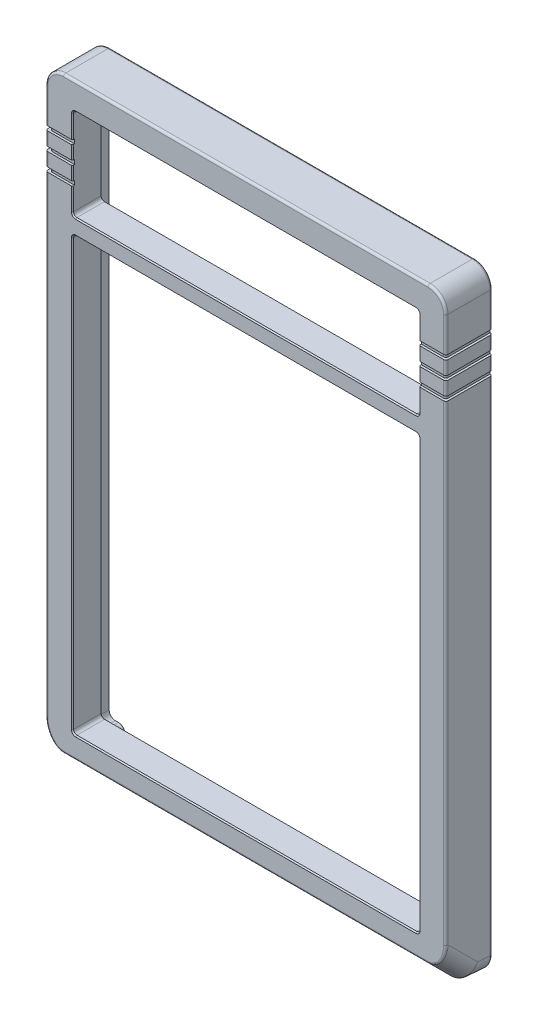
from build123d import *

# Parameters (mm, degrees)
EXTRUDE_1_DEPTH       = 89.5
SKETCH_2_OUTSIDE_W    = 124.308
SKETCH_2_OUTSIDE_H    = 171.808
SKETCH_2_OUTSIDE_W_2  = 86.3
SKETCH_2_OUTSIDE_H_2  = 133.9
CUT_EXTRUDE_1_DEPTH   = 1
SKETCH_5_R            = 0.9
CUT_EXTRUDE_3_DEPTH   = 6
CUT_EXTRUDE_4_DEPTH   = 5
FILLET_1_R            = 1.4
FILLET_2_R            = 1.4
SKETCH_3_W            = 77.5
SKETCH_3_H            = 96.7
SKETCH_3_H_2          = 20.5
CUT_EXTRUDE_2_DEPTH   = 11.4
FILLET_9_R            = 0.75
FILLET_4_R            = 4
FILLET_7_R            = 2.2
FILLET_8_R            = 0.5
CHAMFER_1_SIZE        = 0.25
SKETCH_7_W            = 102.586971925
SKETCH_7_H            = 1
SKETCH_7_W_2          = 99.317091084
SKETCH_7_W_3          = 97.717091046
CUT_EXTRUDE_1_2_DEPTH = 0.5
SKETCH_8_W            = 14.455899317
SKETCH_8_H            = 1
SKETCH_8_W_2          = 13.955899317
SKETCH_8_W_3          = 15.127945799
CUT_EXTRUDE_2_2_DEPTH = 0.5
SKETCH_9_W            = 13.549012079
SKETCH_9_H            = 1
SKETCH_9_W_2          = 13.424709216
CUT_EXTRUDE_3_2_DEPTH = 0.5
FILLET_10_R           = 0.5


with BuildPart() as part:
    # 草图1 → 凸台-拉伸1 (new body)
    with BuildSketch(Plane(origin=(0, 0, 0), x_dir=(0, 0, -1), z_dir=(1, 0, 0))):
        Polygon((0, 0), (0, 137), (-11.4, 137), (-11.4, 5.716942107), (-6.13205448, 0.448996588), (-1, 0), align=None)
    extrude(amount=EXTRUDE_1_DEPTH)

    # 草图2 outside → Cut-Extrude 1 (cut)
    with BuildSketch(Plane(origin=(0, 0, 0), x_dir=(-1, 0, 0), z_dir=(0, 0, -1))):
        with Locations((-44.75, 68.5)):
            Rectangle(SKETCH_2_OUTSIDE_W, SKETCH_2_OUTSIDE_H)
        with Locations((-44.75, 68.45)):
            Rectangle(SKETCH_2_OUTSIDE_W_2, SKETCH_2_OUTSIDE_H_2, mode=Mode.SUBTRACT)
    extrude(amount=-CUT_EXTRUDE_1_DEPTH, mode=Mode.SUBTRACT)

    # 草图5 → Cut-Extrude 3 (cut)
    with BuildSketch(Plane(origin=(0, 0, 0), x_dir=(-1, 0, 0), z_dir=(0, 0, -1))):
        with Locations((-84.95, 4.55)):
            Circle(SKETCH_5_R)
        with Locations((-4.55, 4.55)):
            Circle(SKETCH_5_R)
        with Locations((-4.55, 132.45)):
            Circle(SKETCH_5_R)
        with Locations((-84.95, 132.45)):
            Circle(SKETCH_5_R)
    extrude(amount=-CUT_EXTRUDE_3_DEPTH, mode=Mode.SUBTRACT)

    # 草图6 → 切除-拉伸4 (cut)
    with BuildSketch(Plane(origin=(0, 0, 0), x_dir=(-1, 0, 0), z_dir=(0, 0, -1))):
        Polygon((-83.2, 2.7), (-6.3, 2.7), (-6.3, 6.2), (-2.8, 6.2), (-2.8, 70.55), (-2.8, 130.7), (-6.3, 130.7), (-6.3, 134.2), (-83.2, 134.2), (-83.2, 130.7), (-86.7, 130.7), (-86.7, 74.35), (-86.7, 6.2), (-83.2, 6.2), align=None)
    extrude(amount=-CUT_EXTRUDE_4_DEPTH, mode=Mode.SUBTRACT)

    # 圆角1
    fillet_1_edges = [part.edges().sort_by_distance(p)[0] for p in [
        (83.2, 2.7, 2.5),
        (86.7, 6.2, 2.5),
        (86.7, 130.7, 2.5),
        (83.2, 134.2, 2.5),
        (6.3, 134.2, 2.5),
        (2.8, 130.7, 2.5),
        (2.8, 6.2, 2.5),
        (6.3, 2.7, 2.5),
    ]]
    fillet(fillet_1_edges, radius=FILLET_1_R)

    # 圆角2
    fillet_2_edges = [part.edges().sort_by_distance(p)[0] for p in [
        (83.2, 6.2, 2.5),
        (83.2, 130.7, 2.5),
        (6.3, 130.7, 2.5),
        (6.3, 6.2, 2.5),
    ]]
    fillet(fillet_2_edges, radius=FILLET_2_R)

    # 草图3 → Cut-Extrude 2 (cut)
    with BuildSketch(Plane(origin=(0, 0, 0), x_dir=(-1, 0, 0), z_dir=(0, 0, -1))):
        with Locations((-44.75, 58.6)):
            Rectangle(SKETCH_3_W, SKETCH_3_H)
        with Locations((-44.75, 120.75)):
            Rectangle(SKETCH_3_W, SKETCH_3_H_2)
    extrude(amount=-CUT_EXTRUDE_2_DEPTH, mode=Mode.SUBTRACT)

    # 圆角9
    fillet_9_edges = [part.edges().sort_by_distance(p)[0] for p in [
        (6, 106.95, 8.2),
        (6, 10.25, 8.2),
        (83.5, 10.25, 8.2),
        (83.5, 106.95, 8.2),
        (83.5, 110.5, 8.2),
        (83.5, 131, 8.2),
        (6, 131, 8.2),
        (6, 110.5, 8.2),
    ]]
    fillet(fillet_9_edges, radius=FILLET_9_R)

    # 圆角4
    fillet_4_edges = [part.edges().sort_by_distance(p)[0] for p in [
        (0, 137, 6.2),
        (89.5, 137, 6.2),
        (89.5, 3.082969348, 8.76602724),
        (89.5, 0.224498294, 3.56602724),
        (0, 0.224498294, 3.56602724),
        (0, 3.082969348, 8.76602724),
    ]]
    fillet(fillet_4_edges, radius=FILLET_4_R)

    # 圆角7
    fillet_7_edges = [part.edges().sort_by_distance(p)[0] for p in [
        (87.9, 135.4, 0.5),
        (1.6, 135.4, 0.5),
        (1.6, 1.5, 0.5),
        (87.9, 1.5, 0.5),
    ]]
    fillet(fillet_7_edges, radius=FILLET_7_R)

    # 圆角8
    fillet_8_edges = [part.edges().sort_by_distance(p)[0] for p in [
        (89.5, 68.507639675, 1),
        (89.5, 72.186898178, 11.4),
        (44.75, 0.448996588, 6.13205448),
        (44.75, 5.716942107, 11.4),
        (0, 72.186898178, 11.4),
        (44.75, 137, 11.4),
        (88.328427125, 135.828427125, 11.4),
        (1.171572875, 135.828427125, 11.4),
        (0.946815933, 7.71919185, 11.4),
        (88.553184067, 7.71919185, 11.4),
        (44.75, 0, 1),
        (0, 68.507639675, 1),
        (44.75, 137, 1),
        (88.328427125, 135.828427125, 1),
        (1.171572875, 135.828427125, 1),
        (1.168878288, 1.178755553, 1),
        (88.331121712, 1.178755553, 1),
        (88.372004479, 1.621633445, 5.585244933),
        (1.127995521, 1.621633445, 5.585244933),
        (44.75, 1.5, 0),
        (87.9, 68.45, 0),
        (1.6, 68.45, 0),
        (44.75, 135.4, 0),
        (87.255634919, 134.755634919, 0),
        (2.244365081, 134.755634919, 0),
        (87.255634919, 2.144365081, 0),
        (2.244365081, 2.144365081, 0),
    ]]
    fillet(fillet_8_edges, radius=FILLET_8_R)

    # 倒角1
    chamfer_1_edges = [part.edges().sort_by_distance(p)[0] for p in [
        (6, 120.75, 11.4),
        (44.75, 110.5, 11.4),
        (83.5, 120.75, 11.4),
        (44.75, 131, 11.4),
        (83.5, 58.6, 11.4),
        (44.75, 106.95, 11.4),
        (6, 58.6, 11.4),
        (44.75, 10.25, 11.4),
        (6.219669914, 110.719669914, 11.4),
        (83.280330086, 110.719669914, 11.4),
        (6.219669914, 130.780330086, 11.4),
        (83.280330086, 130.780330086, 11.4),
        (83.280330086, 106.730330086, 11.4),
        (6.219669914, 106.730330086, 11.4),
        (6.219669914, 10.469669914, 11.4),
        (83.280330086, 10.469669914, 11.4),
    ]]
    chamfer(chamfer_1_edges, length=CHAMFER_1_SIZE)

    # 草图7 → Cut-Extrude 1 2 (cut)
    with BuildSketch(Plane.XY.offset(11.4)):
        with Locations((44.090920782, 120.75)):
            Rectangle(SKETCH_7_W, SKETCH_7_H)
        with Locations((43.658545504, 124.75)):
            Rectangle(SKETCH_7_W_2, SKETCH_7_H)
        with Locations((44.458545523, 116.75)):
            Rectangle(SKETCH_7_W_3, SKETCH_7_H)
    extrude(amount=-CUT_EXTRUDE_1_2_DEPTH, mode=Mode.SUBTRACT)

    # 草图8 → Cut-Extrude 2 2 (cut)
    with BuildSketch(Plane(origin=(89.5, 0, 0), x_dir=(0, 0, -1), z_dir=(1, 0, 0))):
        with Locations((-7.227949659, 124.75)):
            Rectangle(SKETCH_8_W, SKETCH_8_H)
        with Locations((-7.477949659, 116.75)):
            Rectangle(SKETCH_8_W_2, SKETCH_8_H)
        with Locations((-6.891926417, 120.75)):
            Rectangle(SKETCH_8_W_3, SKETCH_8_H)
    extrude(amount=-CUT_EXTRUDE_2_2_DEPTH, mode=Mode.SUBTRACT)

    # 草图9 → Cut-Extrude 3 2 (cut)
    with BuildSketch(Plane.ZY):
        with Locations((5.610494664, 124.75)):
            Rectangle(SKETCH_9_W, SKETCH_9_H)
        with Locations((5.610494664, 116.75)):
            Rectangle(SKETCH_9_W, SKETCH_9_H)
        with Locations((5.548343232, 120.75)):
            Rectangle(SKETCH_9_W_2, SKETCH_9_H)
    extrude(amount=-CUT_EXTRUDE_3_2_DEPTH, mode=Mode.SUBTRACT)

    # 圆角10
    fillet_10_edges = [part.edges().sort_by_distance(p)[0] for p in [
        (89, 116.75, 10.9),
        (89, 124.75, 10.9),
        (89, 120.75, 10.9),
        (0.5, 116.75, 10.9),
        (0.5, 124.75, 10.9),
        (0.5, 120.75, 10.9),
    ]]
    fillet(fillet_10_edges, radius=FILLET_10_R)


solid = part.part
